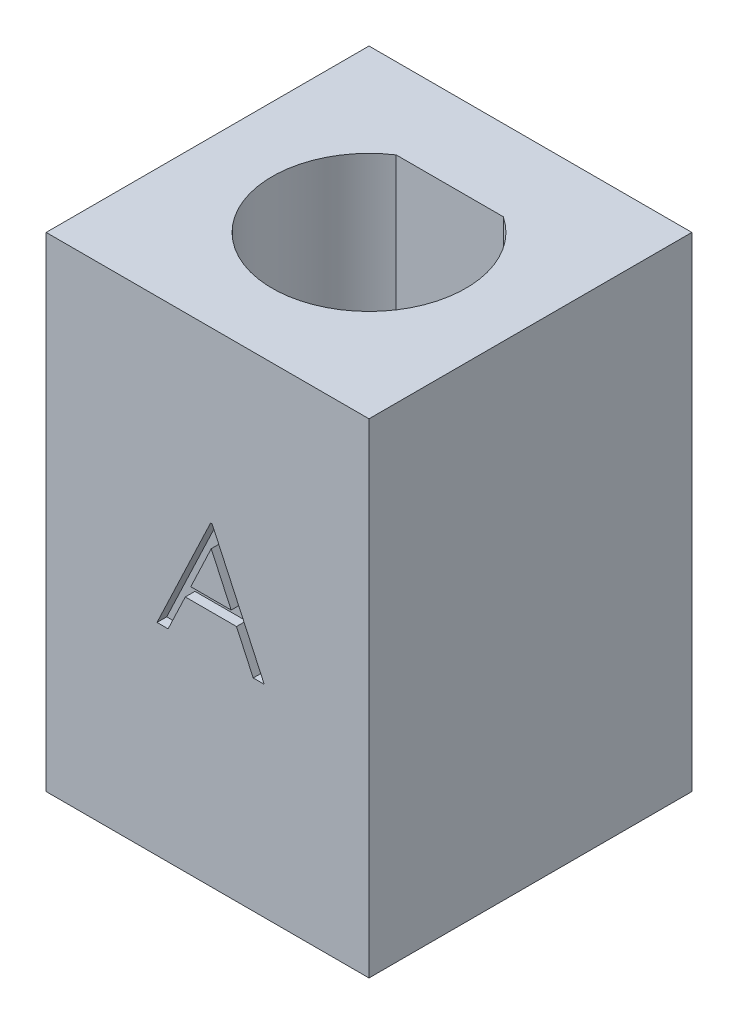
from build123d import *

# Parameters (mm, degrees)
SKETCH1_W           = 10
SKETCH1_H           = 10
BOSS_EXTRUDE1_DEPTH = 15
CUT_EXTRUDE1_DEPTH  = 0.3


with BuildPart() as part:
    # Sketch1 → Boss-Extrude1 (new body)
    with BuildSketch(Plane(origin=(0, 0, 0), x_dir=(1, 0, 0), z_dir=(0, 1, 0))):
        Rectangle(SKETCH1_W, SKETCH1_H)
        with BuildLine():
            Line((-1.658312395, 2.5), (1.658312395, 2.5))
            ThreePointArc((1.658312395, 2.5), (0, -3), (-1.658312395, 2.5))
        make_face(mode=Mode.SUBTRACT)
    extrude(amount=BOSS_EXTRUDE1_DEPTH)

    # Sketch2 → Cut-Extrude1 (cut)
    with BuildSketch(Plane.XY.offset(5)):
        Polygon((0.139535008, 9.754838654), (1.754919623, 6.254838654), (1.413473309, 6.254838654), (0.896045424, 7.376633526), (-0.690593197, 7.376633526), (-1.22274464, 6.254838654), (-1.565593197, 6.254838654), (0.094663213, 9.754838654), align=None)
        Polygon((0.113593501, 9.072647148), (-0.520220601, 7.735607885), (0.730580681, 7.735607885), align=None, mode=Mode.SUBTRACT)
    extrude(amount=-CUT_EXTRUDE1_DEPTH, mode=Mode.SUBTRACT)


solid = part.part
